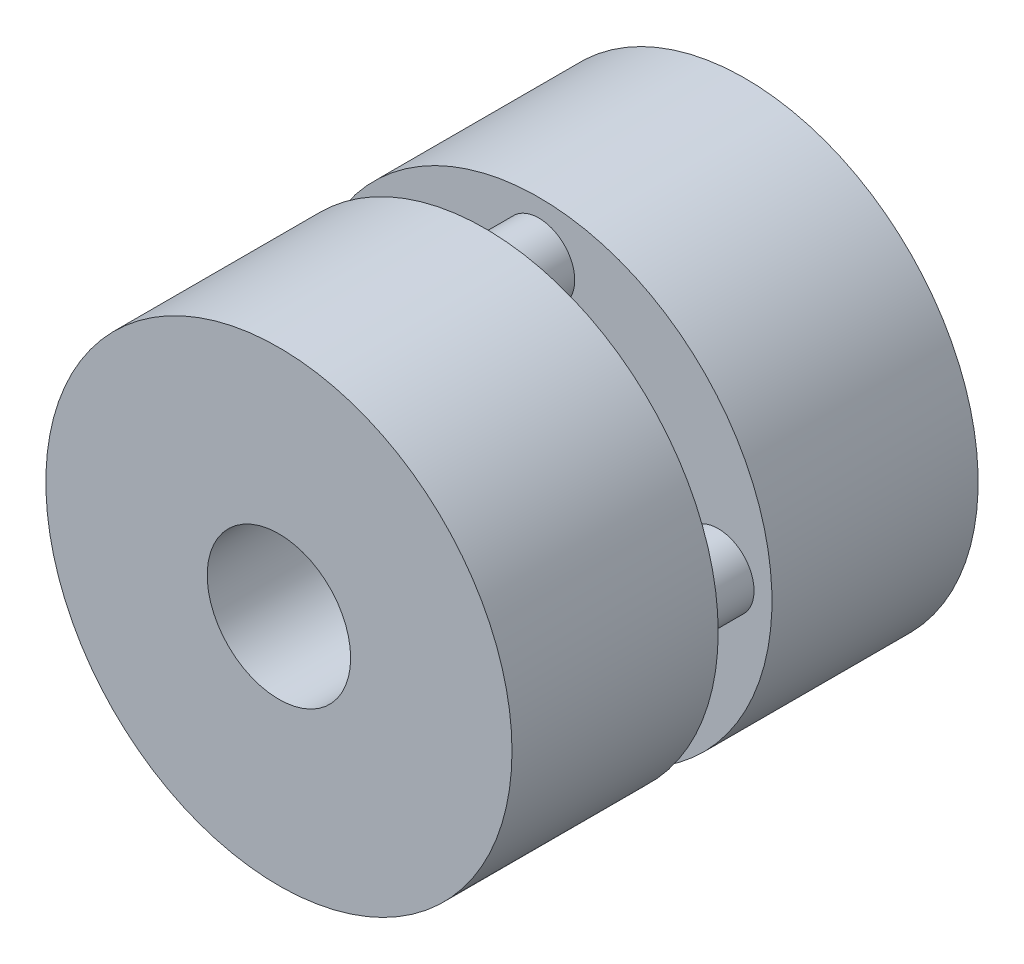
from build123d import *

# Parameters (mm, degrees)
SKETCH1_R           = 13
SKETCH1_R_2         = 4
BOSS_EXTRUDE1_DEPTH = 11.5
SKETCH2_R           = 2
BOSS_EXTRUDE2_DEPTH = 3
SKETCH3_R           = 13
SKETCH3_R_2         = 4
BOSS_EXTRUDE3_DEPTH = 11.5


with BuildPart() as part:
    # Sketch1 → Boss-Extrude1 (new body)
    with BuildSketch(Plane.XY):
        Circle(SKETCH1_R)
        Circle(SKETCH1_R_2, mode=Mode.SUBTRACT)
    extrude(amount=BOSS_EXTRUDE1_DEPTH)

    # Sketch2 → Boss-Extrude2 (add)
    with BuildSketch(Plane(origin=(0, 0, 0), x_dir=(-1, 0, 0), z_dir=(0, 0, -1))):
        with Locations((0, 10)):
            Circle(SKETCH2_R)
        with Locations((10, 0)):
            Circle(SKETCH2_R)
        with Locations((0, -10)):
            Circle(SKETCH2_R)
        with Locations((-10, 0)):
            Circle(SKETCH2_R)
    extrude(amount=BOSS_EXTRUDE2_DEPTH)

    # Sketch3 → Boss-Extrude3 (add)
    with BuildSketch(Plane(origin=(0, 0, -3), x_dir=(-1, 0, 0), z_dir=(0, 0, -1))):
        Circle(SKETCH3_R)
        Circle(SKETCH3_R_2, mode=Mode.SUBTRACT)
    extrude(amount=BOSS_EXTRUDE3_DEPTH)


solid = part.part
